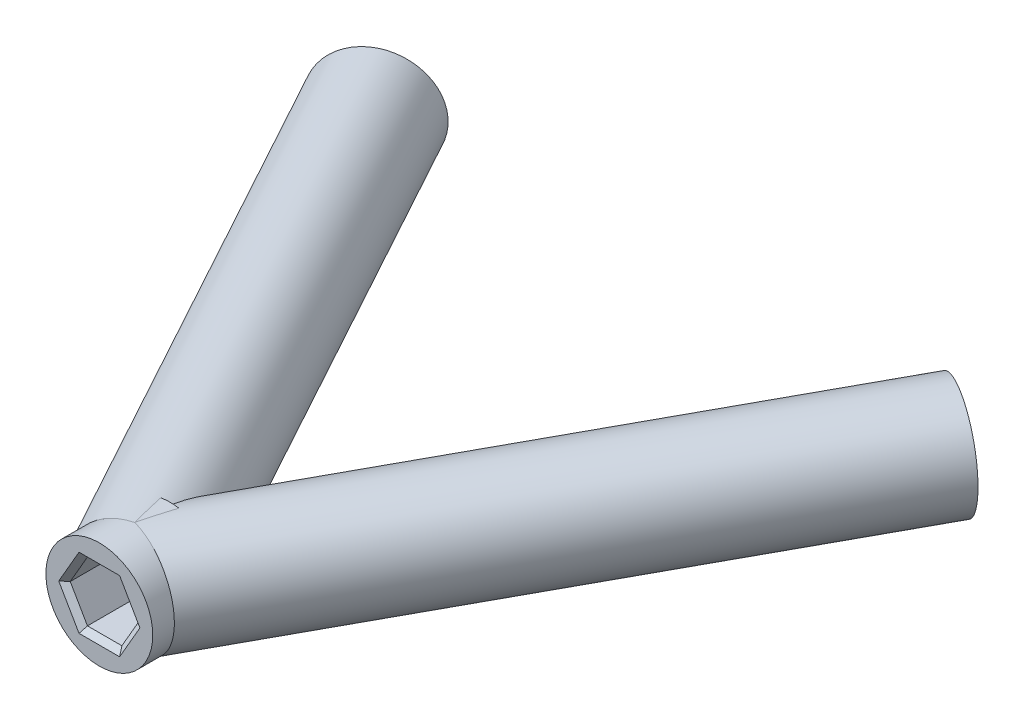
from build123d import *

# Parameters (mm, degrees)
SKETCH1_W          = 5
SKETCH1_H          = 6.6
CUT_EXTRUDE1_DEPTH = 6.6
CUT_EXTRUDE2_DEPTH = 6.6
CUT_EXTRUDE3_DEPTH = 6.6
CHAMFER1_SIZE      = 0.5


with BuildPart() as part:
    # Sketch1 → Revolve-Thin1 (revolve)
    with BuildSketch(Plane(origin=(0, 0, 0), x_dir=(1, 0, 0), z_dir=(0, 1, 0))):
        with Locations((-2.5, 20.8)):
            Rectangle(SKETCH1_W, SKETCH1_H)
    revolve(axis=Axis((0, 0, 0), (0, 0, -1)))

    # Sketch3 → Revolve-Thin2 (revolve)
    with BuildSketch(Plane(origin=(0, 0, 0), x_dir=(1, 0, 0), z_dir=(0, 1, 0))):
        Polygon((-27.192355447, 70.553826822), (0, 20.8), (4.387478051, 23.197923342), (-22.804877396, 72.951750164), align=None)
    revolve(axis=Axis((-27.192355447, 0, -70.553826822), (0.479584668, 0, 0.87749561)))

    # Sketch4 → Revolve-Thin3 (revolve)
    with BuildSketch(Plane(origin=(0, 0, 0), x_dir=(1, 0, 0), z_dir=(0, 1, 0))):
        Polygon((0, 20.8), (27.192355447, 70.553826822), (22.804877396, 72.951750164), (-4.387478051, 23.197923342), align=None)
    revolve(axis=Axis((0, 0, -20.8), (0.479584668, 0, -0.87749561)))

    # Sketch5 → Cut-Extrude1 (cut)
    with BuildSketch(Plane(origin=(-35.945691024, 0, -65.769796576), x_dir=(-0.87749561, 0, 0.479584668), z_dir=(-0.479584668, 0, -0.87749561))):
        Polygon((-7.021637489, 1.286202481), (-9.612383318, 3.201100925), (-12.566106931, 1.914898444), (-12.929084714, -1.286202481), (-10.338338885, -3.201100925), (-7.384615273, -1.914898444), align=None)
    extrude(amount=-CUT_EXTRUDE1_DEPTH, mode=Mode.SUBTRACT)

    # Sketch6 → Cut-Extrude2 (cut)
    with BuildSketch(Plane.XY.offset(-17.5)):
        Polygon((1.610807251, 2.79), (-1.610807251, 2.79), (-3.221614502, 0), (-1.610807251, -2.79), (1.610807251, -2.79), (3.221614502, 0), align=None)
    extrude(amount=-CUT_EXTRUDE2_DEPTH, mode=Mode.SUBTRACT)

    # Sketch7 → Cut-Extrude3 (cut)
    with BuildSketch(Plane(origin=(35.945691024, 0, -65.769796576), x_dir=(-0.87749561, 0, -0.479584668), z_dir=(0.479584668, 0, -0.87749561))):
        Polygon((9.612383318, 3.201100925), (7.021637489, 1.286202481), (7.384615273, -1.914898444), (10.338338885, -3.201100925), (12.929084714, -1.286202481), (12.566106931, 1.914898444), align=None)
    extrude(amount=-CUT_EXTRUDE3_DEPTH, mode=Mode.SUBTRACT)

    # Chamfer1
    chamfer1_edges = [part.edges().sort_by_distance(p)[0] for p in [
        (-29.624979245, -0.314347981, -69.224305553),
        (-28.647550905, 2.243651703, -69.758507252),
        (-26.214927107, 2.557999684, -71.088028522),
        (-24.75973165, 0.314347981, -71.883348091),
        (-25.73715999, -2.243651703, -71.349146391),
        (-28.169783788, -2.557999684, -70.019625122),
        (2.416210877, 1.395, -17.5),
        (0, 2.79, -17.5),
        (-2.416210877, 1.395, -17.5),
        (-2.416210877, -1.395, -17.5),
        (0, -2.79, -17.5),
        (2.416210877, -1.395, -17.5),
        (26.214927107, 2.557999684, -71.088028522),
        (28.647550905, 2.243651703, -69.758507252),
        (29.624979245, -0.314347981, -69.224305553),
        (28.169783788, -2.557999684, -70.019625122),
        (25.73715999, -2.243651703, -71.349146391),
        (24.75973165, 0.314347981, -71.883348091),
    ]]
    chamfer(chamfer1_edges, length=CHAMFER1_SIZE)


solid = part.part
